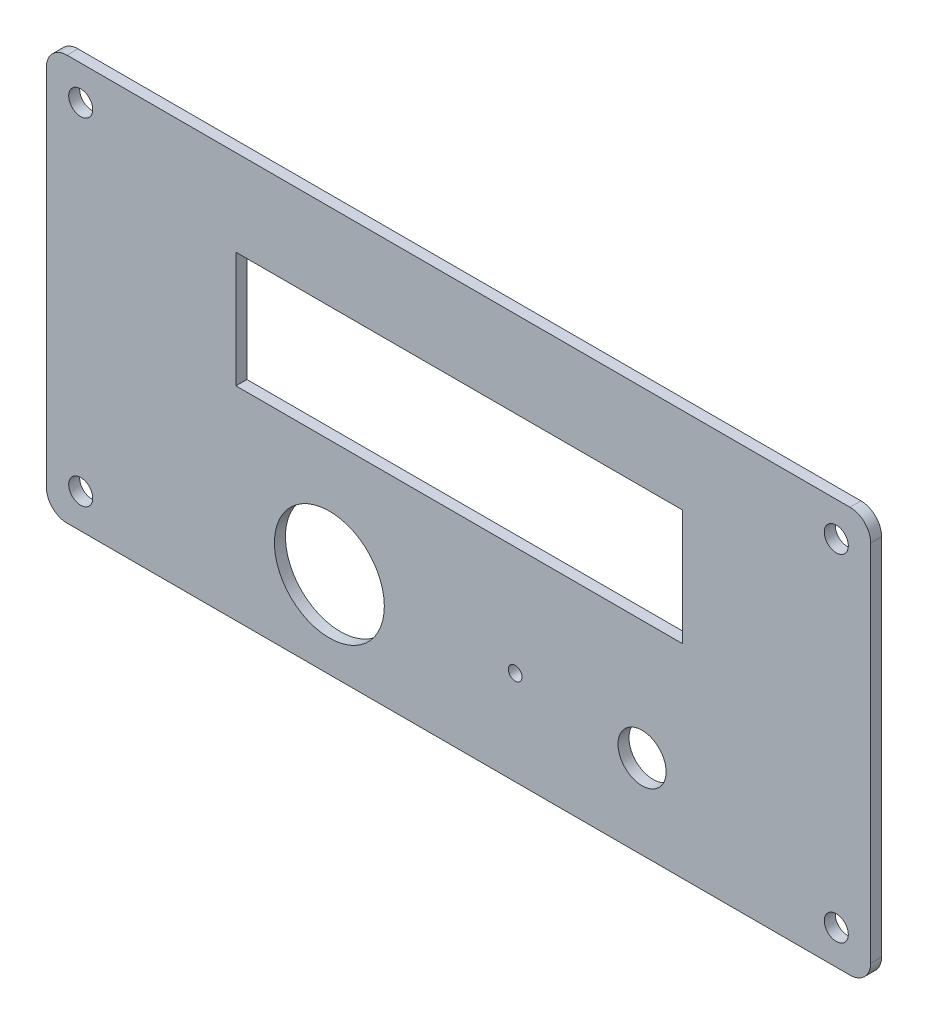
from build123d import *

# Parameters (mm, degrees)
SKETCH_1_R      = 1.75
SKETCH_1_R_2    = 3.5
SKETCH_1_R_3    = 8
SKETCH_1_R_4    = 1
SKETCH_1_W      = 65
SKETCH_1_H      = 16.85
EXTRUDE_1_DEPTH = 1.6


with BuildPart() as part:
    # 草图1 → 凸台-拉伸1 (new body)
    with BuildSketch(Plane.XY):
        with BuildLine():
            Line((-57, 33.073154828), (57, 33.073154828))
            ThreePointArc((57, 33.073154828), (59.121320344, 32.194475172), (60, 30.073154828))
            Line((60, 30.073154828), (60, -22.926845172))
            ThreePointArc((60, -22.926845172), (59.121320344, -25.048165515), (57, -25.926845172))
            Line((57, -25.926845172), (-57, -25.926845172))
            ThreePointArc((-57, -25.926845172), (-59.121320344, -25.048165515), (-60, -22.926845172))
            Line((-60, -22.926845172), (-60, 30.073154828))
            ThreePointArc((-60, 30.073154828), (-59.121320344, 32.194475172), (-57, 33.073154828))
        make_face()
        with Locations((-55, -20.926845172)):
            Circle(SKETCH_1_R, mode=Mode.SUBTRACT)
        with Locations((55, -20.926845172)):
            Circle(SKETCH_1_R, mode=Mode.SUBTRACT)
        with Locations((55, 28.073154828)):
            Circle(SKETCH_1_R, mode=Mode.SUBTRACT)
        with Locations((-55, 28.073154828)):
            Circle(SKETCH_1_R, mode=Mode.SUBTRACT)
        with Locations((26.721118862, -13.682497654)):
            Circle(SKETCH_1_R_2, mode=Mode.SUBTRACT)
        with Locations((-18.798880758, -13.312497654)):
            Circle(SKETCH_1_R_3, mode=Mode.SUBTRACT)
        with Locations((8.251119242, -12.222497654)):
            Circle(SKETCH_1_R_4, mode=Mode.SUBTRACT)
        with Locations((0.097411242, 12.102502346)):
            Rectangle(SKETCH_1_W, SKETCH_1_H, mode=Mode.SUBTRACT)
    extrude(amount=EXTRUDE_1_DEPTH)


solid = part.part
